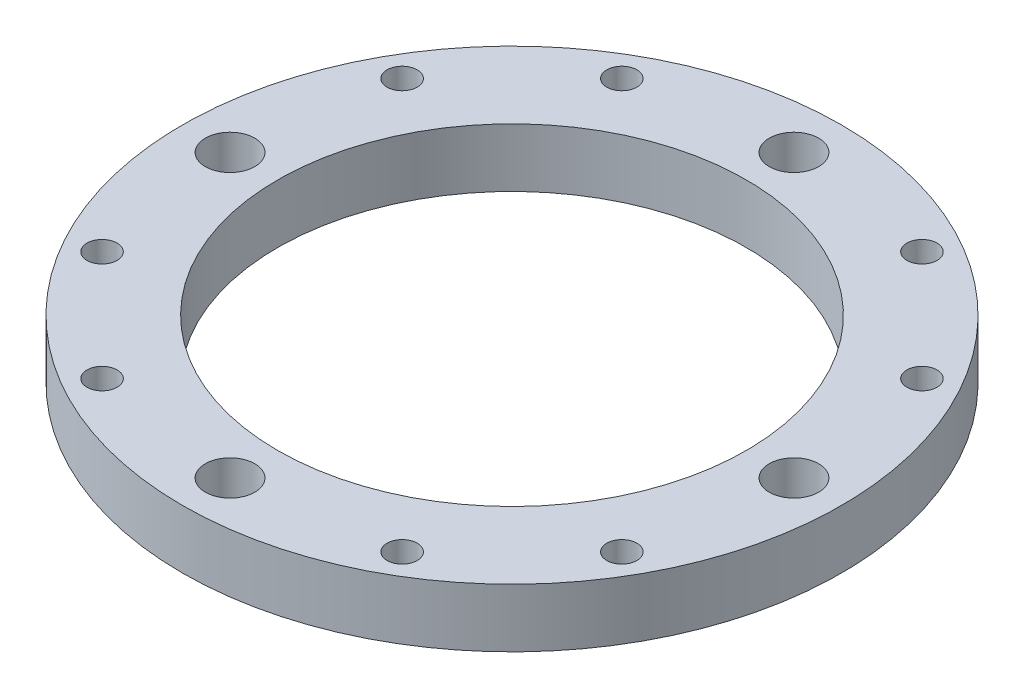
from build123d import *

# Parameters (mm, degrees)
SKETCH1_R               = 71.4375
SKETCH1_R_2             = 50.8
BOSS_EXTRUDE1_DEPTH     = 12.7
F_1_2_13_TAPPED_HOLE1_D = 10.71626
SKETCH5_R               = 3.2639
CUT_EXTRUDE1_DEPTH      = 13.7


with BuildPart() as part:
    # Sketch1 → Boss-Extrude1 (new body)
    with BuildSketch(Plane(origin=(0, 0, 0), x_dir=(1, 0, 0), z_dir=(0, 1, 0))):
        Circle(SKETCH1_R)
        Circle(SKETCH1_R_2, mode=Mode.SUBTRACT)
    extrude(amount=BOSS_EXTRUDE1_DEPTH)

    # 1_2-13 Tapped Hole1 (through all)
    with Locations(Plane(origin=(0, 12.7, 0), x_dir=(1, 0, 0), z_dir=(0, 1, 0))):
        with Locations((-61.11875, 0), (0, 61.11875), (61.11875, 0), (0, -61.11875)):
            Hole(F_1_2_13_TAPPED_HOLE1_D / 2)

    # Sketch5 → Cut-Extrude1 (cut, through all)
    with BuildSketch(Plane(origin=(0, 12.7, 0), x_dir=(1, 0, 0), z_dir=(0, 1, 0))):
        with Locations((-32.5270495, 56.338502354)):
            Circle(SKETCH5_R)
        with Locations((32.5270495, 56.338502354)):
            Circle(SKETCH5_R)
        with Locations((56.338502354, 32.5270495)):
            Circle(SKETCH5_R)
        with Locations((56.338502354, -32.5270495)):
            Circle(SKETCH5_R)
        with Locations((32.5270495, -56.338502354)):
            Circle(SKETCH5_R)
        with Locations((-32.5270495, -56.338502354)):
            Circle(SKETCH5_R)
        with Locations((-56.338502354, -32.5270495)):
            Circle(SKETCH5_R)
        with Locations((-56.338502354, 32.5270495)):
            Circle(SKETCH5_R)
    extrude(amount=-CUT_EXTRUDE1_DEPTH, mode=Mode.SUBTRACT)


solid = part.part
